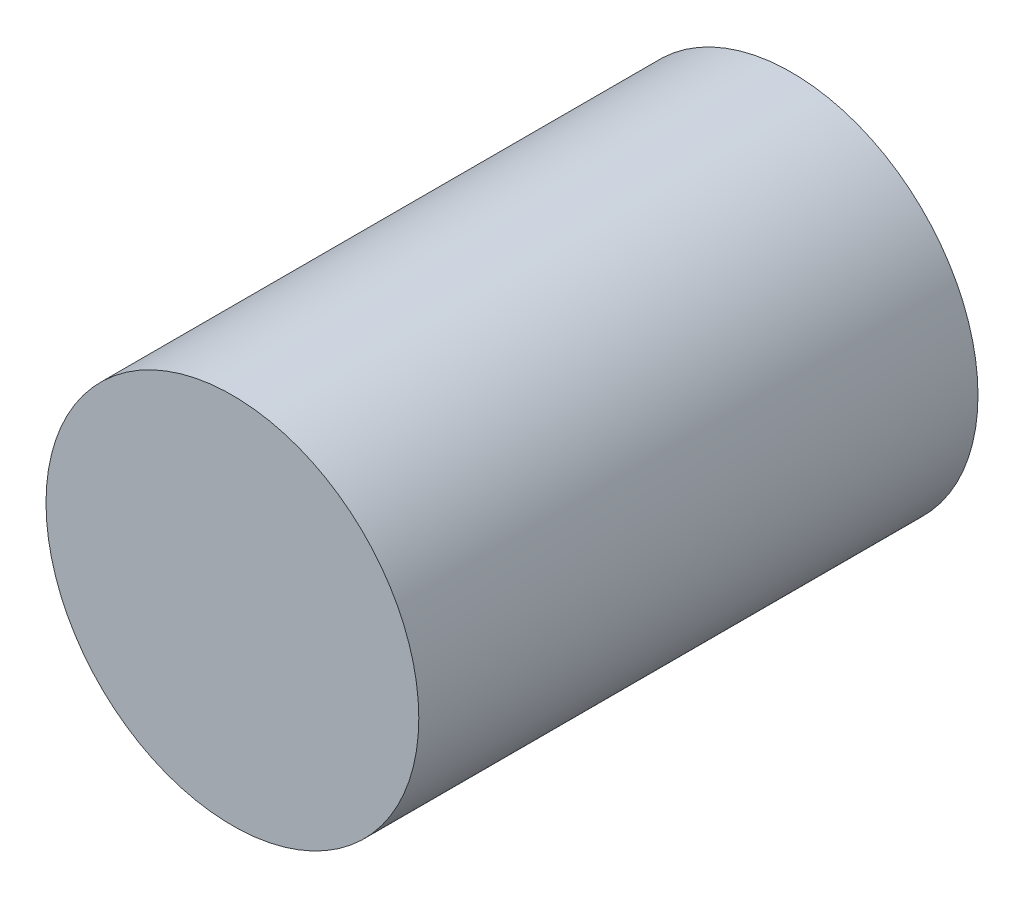
from build123d import *

# Parameters (mm, degrees)
SKETCH1_R           = 2
BOSS_EXTRUDE1_DEPTH = 6


with BuildPart() as part:
    # Sketch1 → Boss-Extrude1 (new body)
    with BuildSketch(Plane.XY):
        Circle(SKETCH1_R)
    extrude(amount=BOSS_EXTRUDE1_DEPTH)


solid = part.part
